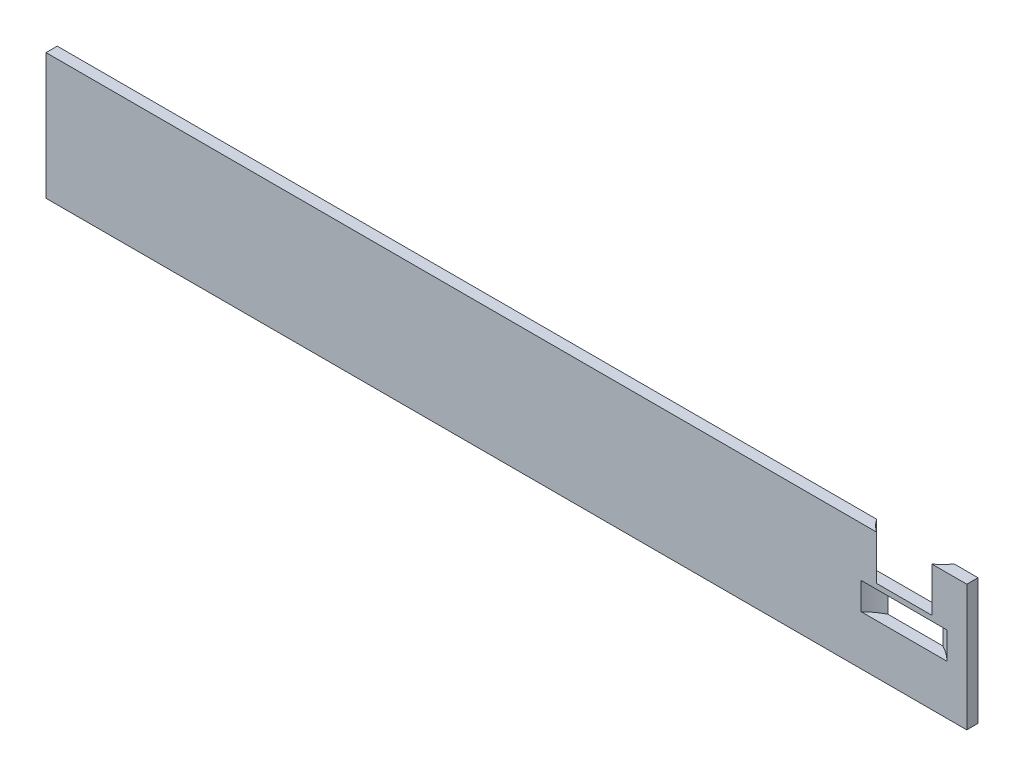
from build123d import *

# Parameters (mm, degrees)
CROQUIS1_W              = 985
CROQUIS1_H              = 135
SALIENTE_EXTRUIR1_DEPTH = 12
CORTAR_EXTRUIR1_DEPTH   = 47.5
CROQUIS3_R              = 65
CORTAR_EXTRUIR2_DEPTH   = 29


with BuildPart() as part:
    # Croquis1 → Saliente-Extruir1 (new body)
    with BuildSketch(Plane.XY):
        with Locations((-492.5, 67.5)):
            Rectangle(CROQUIS1_W, CROQUIS1_H)
    extrude(amount=SALIENTE_EXTRUIR1_DEPTH)

    # Croquis2 → Cortar-Extruir1 (cut)
    with BuildSketch(Plane(origin=(0, 135, 0), x_dir=(1, 0, 0), z_dir=(0, 1, 0))):
        with BuildLine():
            Line((-25.534833896, 0), (-108.465166104, 0))
            ThreePointArc((-108.465166104, 0), (-103.062225626, -6.494730354), (-96.654004789, -12))
            Line((-96.654004789, -12), (-37.345995211, -12))
            ThreePointArc((-37.345995211, -12), (-30.937774374, -6.494730354), (-25.534833896, 0))
        make_face()
    extrude(amount=-CORTAR_EXTRUIR1_DEPTH, mode=Mode.SUBTRACT)

    # Croquis3 → Cortar-Extruir2 (cut)
    with BuildSketch(Plane(origin=(0, 82, 0), x_dir=(1, 0, 0), z_dir=(0, 1, 0))):
        with Locations((-67, -58)):
            Circle(CROQUIS3_R)
    extrude(amount=-CORTAR_EXTRUIR2_DEPTH, mode=Mode.SUBTRACT)


solid = part.part
